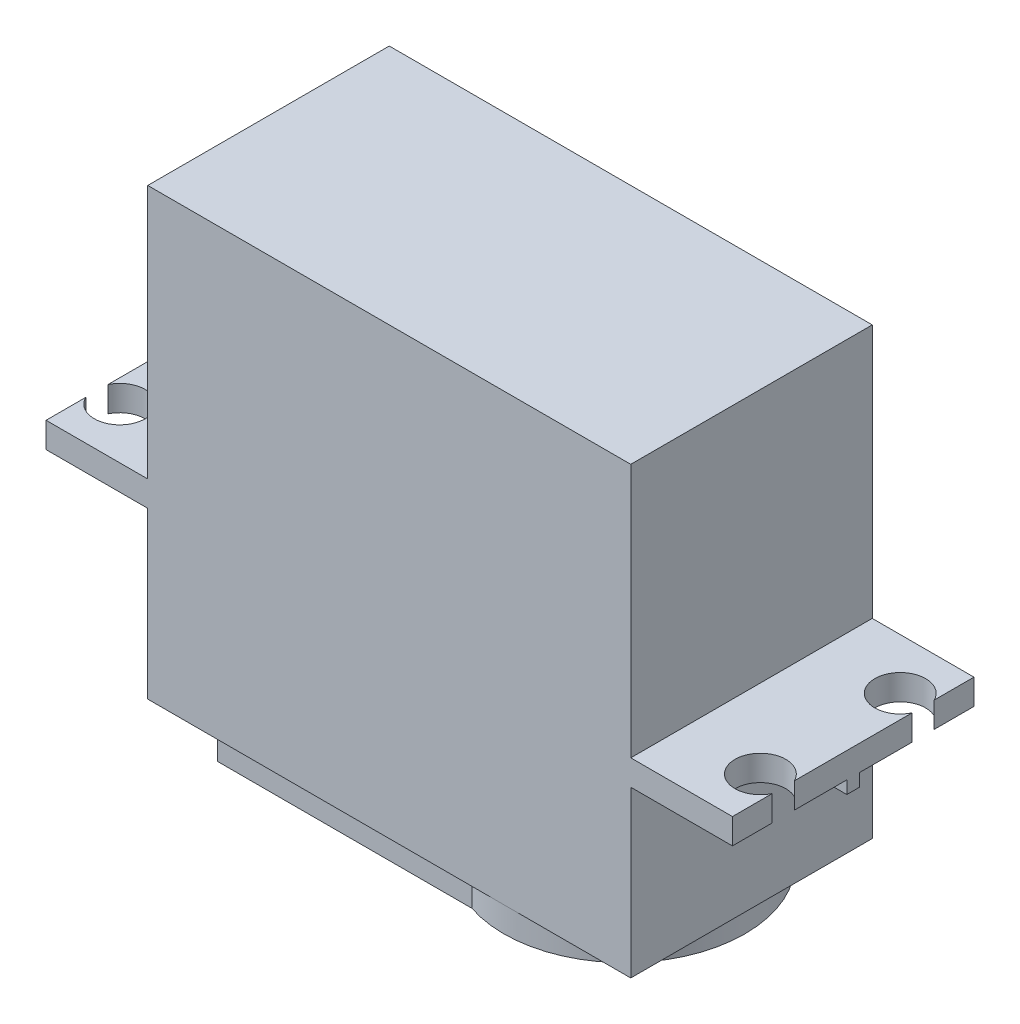
from build123d import *

# Parameters (mm, degrees)
BOSS_EXTRUDE1_DEPTH  = 19
SKETCH6_R            = 2
CUT_EXTRUDE2_DEPTH   = 16
SKETCH10_W           = 8
SKETCH10_H           = 1
BOSS_EXTRUDE14_DEPTH = 1
BOSS_EXTRUDE15_DEPTH = 2
SKETCH13_R           = 3
CUT_EXTRUDE3_DEPTH   = 5


with BuildPart() as part:
    # Sketch1 → Boss-Extrude1 (new body)
    with BuildSketch(Plane.XY):
        Polygon((19, 0), (-19, 0), (-19, 13), (-27, 13), (-27, 15), (-19, 15), (-19, 35), (19, 35), (19, 15), (27, 15), (27, 13), (19, 13), align=None)
    extrude(amount=BOSS_EXTRUDE1_DEPTH)

    # Sketch6 → Cut-Extrude2 (cut, through all)
    with BuildSketch(Plane(origin=(0, 15, 0), x_dir=(1, 0, 0), z_dir=(0, 1, 0))):
        with Locations((25.2, -15)):
            Circle(SKETCH6_R)
        with Locations((25.2, -4)):
            Circle(SKETCH6_R)
        with Locations((-25.2, -4)):
            Circle(SKETCH6_R)
        with Locations((-25.2, -15)):
            Circle(SKETCH6_R)
    extrude(amount=-CUT_EXTRUDE2_DEPTH, mode=Mode.SUBTRACT)

    # Sketch10 → Boss-Extrude14 (add)
    with BuildSketch(Plane.XZ.offset(-13)):
        with Locations((-23, 9.5)):
            Rectangle(SKETCH10_W, SKETCH10_H)
        with Locations((23, 9.5)):
            Rectangle(SKETCH10_W, SKETCH10_H)
    extrude(amount=BOSS_EXTRUDE14_DEPTH)

    # Sketch12 → Boss-Extrude15 (add)
    with BuildSketch(Plane.XZ):
        with BuildLine():
            Line((-14, 18.5), (6, 18.5))
            ThreePointArc((6, 18.5), (18.486832981, 9.5), (6, 0.5))
            Line((6, 0.5), (-14, 0.5))
            Line((-14, 0.5), (-14, 18.5))
        make_face()
    extrude(amount=BOSS_EXTRUDE15_DEPTH)

    # Sketch13 → Cut-Extrude3 (cut)
    with BuildSketch(Plane.XZ.offset(2)):
        with Locations((9, 9.5)):
            Circle(SKETCH13_R)
    extrude(amount=-CUT_EXTRUDE3_DEPTH, mode=Mode.SUBTRACT)


solid = part.part
